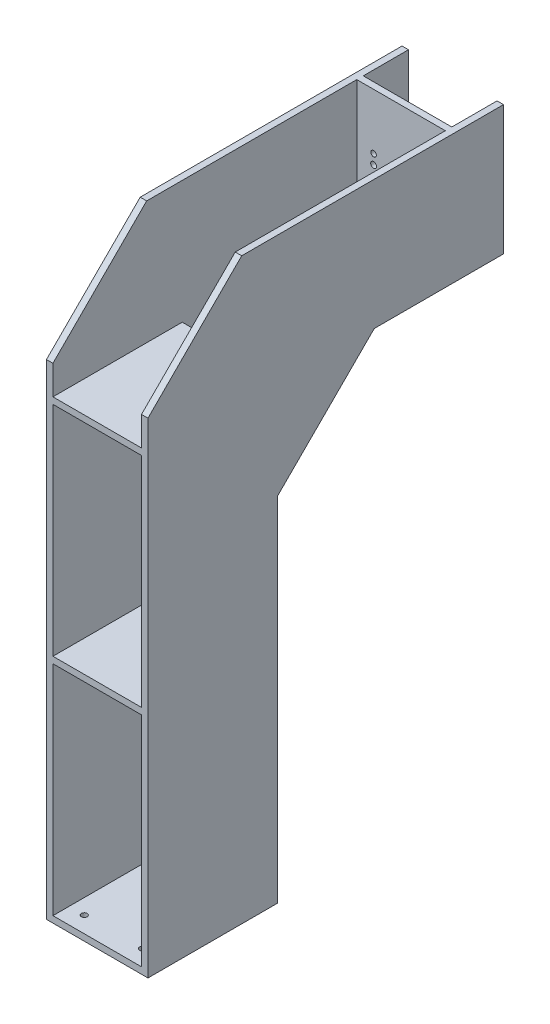
from build123d import *

# Parameters (mm, degrees)
BOSS_EXTRUDE1_DEPTH      = 10
BOSS_EXTRUDE1_DEPTH_BACK = 147
SKETCH3_W                = 137
SKETCH3_H                = 550
CUT_EXTRUDE1_DEPTH       = 885
SKETCH4_W                = 137
SKETCH4_H                = 200
BOSS_EXTRUDE2_DEPTH      = 10
CUT_EXTRUDE3_REACH       = 82
SKETCH6_R                = 4.5
SKETCH6_R_2              = 8
SKETCH6_R_3              = 4.25
SKETCH8_W                = 157
SKETCH8_H                = 200
BOSS_EXTRUDE3_DEPTH      = 10
LPATTERN1_COUNT          = 3
LPATTERN1_PITCH          = 347.5
CUT_EXTRUDE4_REACH       = 12
SKETCH7_R                = 4.5
SKETCH7_R_2              = 4.25


with BuildPart() as part:
    # Sketch1 → Boss-Extrude1 (new body, two sides)
    with BuildSketch(Plane(origin=(0, 0, 0), x_dir=(0, 0, -1), z_dir=(1, 0, 0))) as boss_extrude1_sk:
        Polygon((200, 695), (200, 545), (350, 695), align=None)
        Polygon((200, 0), (200, 695), (550, 695), (550, 895), (145, 895), (0, 750), (0, 0), align=None)
    extrude(amount=BOSS_EXTRUDE1_DEPTH)
    extrude(boss_extrude1_sk.sketch, amount=-BOSS_EXTRUDE1_DEPTH_BACK)

    # Sketch3 → Cut-Extrude1 (cut)
    with BuildSketch(Plane(origin=(0, 895, 0), x_dir=(1, 0, 0), z_dir=(0, 1, 0))):
        with Locations((-68.5, 275)):
            Rectangle(SKETCH3_W, SKETCH3_H)
    extrude(amount=-CUT_EXTRUDE1_DEPTH, mode=Mode.SUBTRACT)

    # Sketch4 → Boss-Extrude2 (add)
    with BuildSketch(Plane(origin=(0, 0, -480), x_dir=(-1, 0, 0), z_dir=(0, 0, -1))):
        with Locations((68.5, 795)):
            Rectangle(SKETCH4_W, SKETCH4_H)
    extrude(amount=-BOSS_EXTRUDE2_DEPTH)

    # Sketch6 → Cut-Extrude3 (cut, up to next)
    with BuildSketch(Plane.XY.offset(-470), mode=Mode.PRIVATE) as cut_extrude3_sk1:
        with Locations((-111, 747.2)):
            Circle(SKETCH6_R)
    cut_extrude3_tool1 = extrude(cut_extrude3_sk1.sketch, amount=-CUT_EXTRUDE3_REACH, mode=Mode.PRIVATE) & part.part
    add(cut_extrude3_tool1.solids().sort_by_distance((-111, 747.2, -470))[0], mode=Mode.SUBTRACT)
    # Sketch6 → Cut-Extrude3 (cut, up to next)
    with BuildSketch(Plane.XY.offset(-470), mode=Mode.PRIVATE) as cut_extrude3_sk2:
        with Locations((-26, 747.2)):
            Circle(SKETCH6_R)
    cut_extrude3_tool2 = extrude(cut_extrude3_sk2.sketch, amount=-CUT_EXTRUDE3_REACH, mode=Mode.PRIVATE) & part.part
    add(cut_extrude3_tool2.solids().sort_by_distance((-26, 747.2, -470))[0], mode=Mode.SUBTRACT)
    # Sketch6 → Cut-Extrude3 (cut, up to next)
    with BuildSketch(Plane.XY.offset(-470), mode=Mode.PRIVATE) as cut_extrude3_sk3:
        with Locations((-111, 793.7)):
            Circle(SKETCH6_R)
    cut_extrude3_tool3 = extrude(cut_extrude3_sk3.sketch, amount=-CUT_EXTRUDE3_REACH, mode=Mode.PRIVATE) & part.part
    add(cut_extrude3_tool3.solids().sort_by_distance((-111, 793.7, -470))[0], mode=Mode.SUBTRACT)
    # Sketch6 → Cut-Extrude3 (cut, up to next)
    with BuildSketch(Plane.XY.offset(-470), mode=Mode.PRIVATE) as cut_extrude3_sk4:
        with Locations((-26, 793.7)):
            Circle(SKETCH6_R)
    cut_extrude3_tool4 = extrude(cut_extrude3_sk4.sketch, amount=-CUT_EXTRUDE3_REACH, mode=Mode.PRIVATE) & part.part
    add(cut_extrude3_tool4.solids().sort_by_distance((-26, 793.7, -470))[0], mode=Mode.SUBTRACT)
    # Sketch6 → Cut-Extrude3 (cut, up to next)
    with BuildSketch(Plane.XY.offset(-470), mode=Mode.PRIVATE) as cut_extrude3_sk5:
        with Locations((-63, 788.5)):
            Circle(SKETCH6_R_2)
    cut_extrude3_tool5 = extrude(cut_extrude3_sk5.sketch, amount=-CUT_EXTRUDE3_REACH, mode=Mode.PRIVATE) & part.part
    add(cut_extrude3_tool5.solids().sort_by_distance((-63, 788.5, -470))[0], mode=Mode.SUBTRACT)
    # Sketch6 → Cut-Extrude3 (cut, up to next)
    with BuildSketch(Plane.XY.offset(-470), mode=Mode.PRIVATE) as cut_extrude3_sk6:
        with Locations((-111, 808.7)):
            Circle(SKETCH6_R_3)
    cut_extrude3_tool6 = extrude(cut_extrude3_sk6.sketch, amount=-CUT_EXTRUDE3_REACH, mode=Mode.PRIVATE) & part.part
    add(cut_extrude3_tool6.solids().sort_by_distance((-111, 808.7, -470))[0], mode=Mode.SUBTRACT)
    # Sketch6 → Cut-Extrude3 (cut, up to next)
    with BuildSketch(Plane.XY.offset(-470), mode=Mode.PRIVATE) as cut_extrude3_sk7:
        with Locations((-26, 732.2)):
            Circle(SKETCH6_R_3)
    cut_extrude3_tool7 = extrude(cut_extrude3_sk7.sketch, amount=-CUT_EXTRUDE3_REACH, mode=Mode.PRIVATE) & part.part
    add(cut_extrude3_tool7.solids().sort_by_distance((-26, 732.2, -470))[0], mode=Mode.SUBTRACT)

    # Sketch8 → Boss-Extrude3 (add)
    with BuildSketch(Plane(origin=(0, 705, 0), x_dir=(-1, 0, 0), z_dir=(0, -1, 0))):
        with Locations((68.5, 100)):
            Rectangle(SKETCH8_W, SKETCH8_H)
    boss_extrude3 = extrude(amount=BOSS_EXTRUDE3_DEPTH)

    # LPattern1: Boss-Extrude3 ×3
    with Locations(*[(0, -i * LPATTERN1_PITCH, 0) for i in range(1, LPATTERN1_COUNT)]):
        add(boss_extrude3)

    # Sketch7 → Cut-Extrude4 (cut, up to next)
    with BuildSketch(Plane(origin=(0, 10, 0), x_dir=(1, 0, 0), z_dir=(0, 1, 0)), mode=Mode.PRIVATE) as cut_extrude4_sk1:
        with Locations((-113.5, 175)):
            Circle(SKETCH7_R)
    cut_extrude4_tool1 = extrude(cut_extrude4_sk1.sketch, amount=-CUT_EXTRUDE4_REACH, mode=Mode.PRIVATE) & part.part
    add(cut_extrude4_tool1.solids().sort_by_distance((-113.5, 10, -175))[0], mode=Mode.SUBTRACT)
    # Sketch7 → Cut-Extrude4 (cut, up to next)
    with BuildSketch(Plane(origin=(0, 10, 0), x_dir=(1, 0, 0), z_dir=(0, 1, 0)), mode=Mode.PRIVATE) as cut_extrude4_sk2:
        with Locations((-23.5, 175)):
            Circle(SKETCH7_R)
    cut_extrude4_tool2 = extrude(cut_extrude4_sk2.sketch, amount=-CUT_EXTRUDE4_REACH, mode=Mode.PRIVATE) & part.part
    add(cut_extrude4_tool2.solids().sort_by_distance((-23.5, 10, -175))[0], mode=Mode.SUBTRACT)
    # Sketch7 → Cut-Extrude4 (cut, up to next)
    with BuildSketch(Plane(origin=(0, 10, 0), x_dir=(1, 0, 0), z_dir=(0, 1, 0)), mode=Mode.PRIVATE) as cut_extrude4_sk3:
        with Locations((-23.5, 25)):
            Circle(SKETCH7_R)
    cut_extrude4_tool3 = extrude(cut_extrude4_sk3.sketch, amount=-CUT_EXTRUDE4_REACH, mode=Mode.PRIVATE) & part.part
    add(cut_extrude4_tool3.solids().sort_by_distance((-23.5, 10, -25))[0], mode=Mode.SUBTRACT)
    # Sketch7 → Cut-Extrude4 (cut, up to next)
    with BuildSketch(Plane(origin=(0, 10, 0), x_dir=(1, 0, 0), z_dir=(0, 1, 0)), mode=Mode.PRIVATE) as cut_extrude4_sk4:
        with Locations((-113.5, 25)):
            Circle(SKETCH7_R)
    cut_extrude4_tool4 = extrude(cut_extrude4_sk4.sketch, amount=-CUT_EXTRUDE4_REACH, mode=Mode.PRIVATE) & part.part
    add(cut_extrude4_tool4.solids().sort_by_distance((-113.5, 10, -25))[0], mode=Mode.SUBTRACT)
    # Sketch7 → Cut-Extrude4 (cut, up to next)
    with BuildSketch(Plane(origin=(0, 10, 0), x_dir=(1, 0, 0), z_dir=(0, 1, 0)), mode=Mode.PRIVATE) as cut_extrude4_sk5:
        with Locations((-113.5, 155)):
            Circle(SKETCH7_R_2)
    cut_extrude4_tool5 = extrude(cut_extrude4_sk5.sketch, amount=-CUT_EXTRUDE4_REACH, mode=Mode.PRIVATE) & part.part
    add(cut_extrude4_tool5.solids().sort_by_distance((-113.5, 10, -155))[0], mode=Mode.SUBTRACT)
    # Sketch7 → Cut-Extrude4 (cut, up to next)
    with BuildSketch(Plane(origin=(0, 10, 0), x_dir=(1, 0, 0), z_dir=(0, 1, 0)), mode=Mode.PRIVATE) as cut_extrude4_sk6:
        with Locations((-23.5, 45)):
            Circle(SKETCH7_R_2)
    cut_extrude4_tool6 = extrude(cut_extrude4_sk6.sketch, amount=-CUT_EXTRUDE4_REACH, mode=Mode.PRIVATE) & part.part
    add(cut_extrude4_tool6.solids().sort_by_distance((-23.5, 10, -45))[0], mode=Mode.SUBTRACT)


solid = part.part
